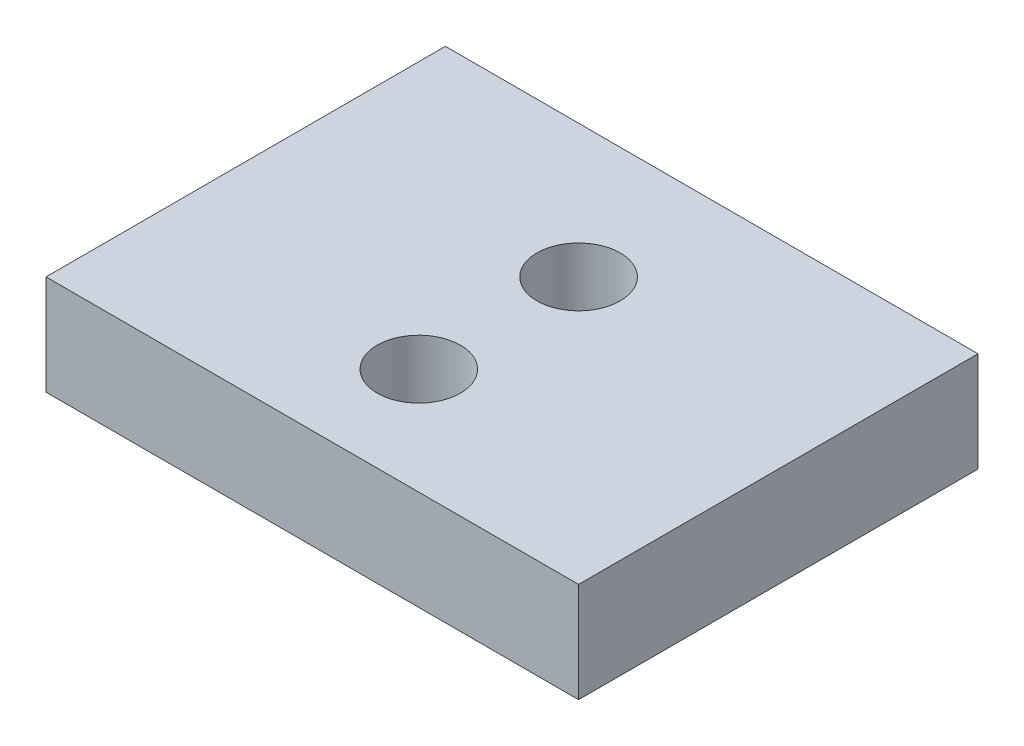
from build123d import *

# Parameters (mm, degrees)
SKETCH1_W                      = 50.8
SKETCH1_H                      = 9.525
BOSS_EXTRUDE1_DEPTH            = 38.1
F_5_16_0_3125_DIAMETER_HOLE1_D = 7.9375
F_8_32_TAPPED_HOLE1_D          = 3.4544
F_8_32_TAPPED_HOLE1_DEPTH      = 25.4
F_8_32_TAPPED_HOLE1_TIP        = 1.037806461


with BuildPart() as part:
    # Sketch1 → Boss-Extrude1 (new body)
    with BuildSketch(Plane.XY):
        Rectangle(SKETCH1_W, SKETCH1_H)
    extrude(amount=BOSS_EXTRUDE1_DEPTH)

    # 5/16 (0.3125) Diameter Hole1 (through all)
    with Locations(Plane(origin=(0, -4.7625, 0), x_dir=(-1, 0, 0), z_dir=(0, -1, 0))):
        with Locations((0, -12.7), (0, -27.94)):
            Hole(F_5_16_0_3125_DIAMETER_HOLE1_D / 2)

    # #8-32 Tapped Hole1
    with Locations(Plane(origin=(0, 0, 0), x_dir=(-1, 0, 0), z_dir=(0, 0, -1))):
        with Locations((-12.7, 0), (12.7, 0)):
            Hole(F_8_32_TAPPED_HOLE1_D / 2, depth=F_8_32_TAPPED_HOLE1_DEPTH)
            with Locations((0, 0, -(F_8_32_TAPPED_HOLE1_DEPTH + F_8_32_TAPPED_HOLE1_TIP / 2))):  # 118° drill point
                Cone(0, F_8_32_TAPPED_HOLE1_D / 2, F_8_32_TAPPED_HOLE1_TIP, mode=Mode.SUBTRACT)


solid = part.part
